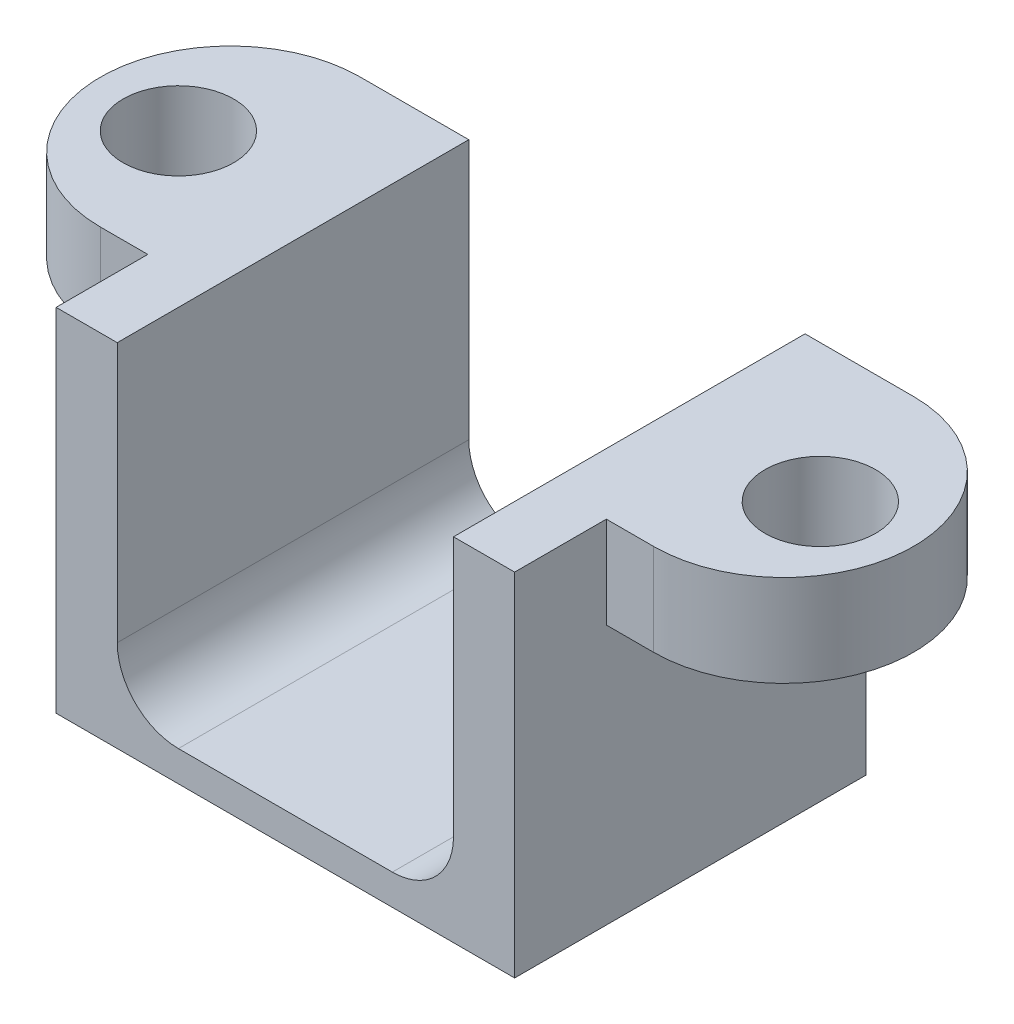
from build123d import *

# Parameters (mm, degrees)
SKETCH1_W           = 15
SKETCH1_H           = 11.5
BOSS_EXTRUDE1_DEPTH = 11.5
SKETCH3_W           = 11
SKETCH3_H           = 10.5
CUT_EXTRUDE1_DEPTH  = 11.5
FILLET1_R           = 2
BOSS_EXTRUDE2_DEPTH = 3
SKETCH5_R           = 1.809208309
CUT_EXTRUDE2_DEPTH  = 3


with BuildPart() as part:
    # Sketch1 → Boss-Extrude1 (new body)
    with BuildSketch(Plane.XY):
        with Locations((7.5, 5.75)):
            Rectangle(SKETCH1_W, SKETCH1_H)
    extrude(amount=BOSS_EXTRUDE1_DEPTH)

    # Sketch3 → Cut-Extrude1 (cut)
    with BuildSketch(Plane.XY.offset(11.5)):
        with Locations((7.5, 6.25)):
            Rectangle(SKETCH3_W, SKETCH3_H)
    extrude(amount=-CUT_EXTRUDE1_DEPTH, mode=Mode.SUBTRACT)

    # Fillet1
    fillet1_edges = [part.edges().sort_by_distance(p)[0] for p in [
        (2, 1, 5.75),
        (13, 1, 5.75),
    ]]
    fillet(fillet1_edges, radius=FILLET1_R)

    # Sketch4 → Boss-Extrude2 (add)
    with BuildSketch(Plane(origin=(0, 11.5, 0), x_dir=(1, 0, 0), z_dir=(0, 1, 0))):
        with BuildLine():
            Line((0, 0), (-1.55, 0))
            ThreePointArc((-1.55, 0), (-5.8, -4.25), (-1.55, -8.5))
            Line((-1.55, -8.5), (0, -8.5))
            Line((0, -8.5), (0, 0))
        make_face()
        with BuildLine():
            Line((15, 0), (16.55, 0))
            ThreePointArc((16.55, 0), (20.8, -4.25), (16.55, -8.5))
            Line((16.55, -8.5), (15, -8.5))
            Line((15, -8.5), (15, 0))
        make_face()
    extrude(amount=-BOSS_EXTRUDE2_DEPTH)

    # Sketch5 → Cut-Extrude2 (cut)
    with BuildSketch(Plane(origin=(0, 11.5, 0), x_dir=(1, 0, 0), z_dir=(0, 1, 0))):
        with Locations((-3, -4.5)):
            Circle(SKETCH5_R)
    cut_extrude2 = extrude(amount=-CUT_EXTRUDE2_DEPTH, mode=Mode.SUBTRACT)

    # Mirror1: Cut-Extrude2 across plane
    add(cut_extrude2.mirror(Plane.ZY.offset(-7.5)), mode=Mode.SUBTRACT)


solid = part.part
